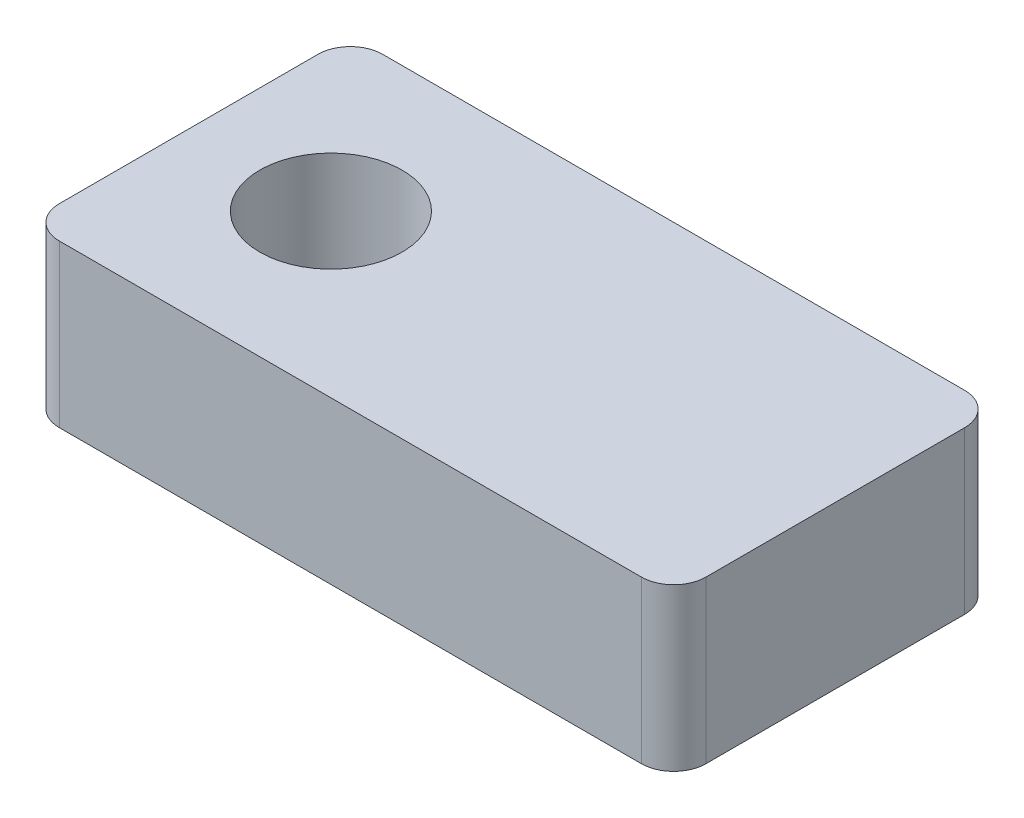
from build123d import *

# Parameters (mm, degrees)
SKETCH1_W           = 10
SKETCH1_H           = 5
SKETCH1_R           = 1.1
BOSS_EXTRUDE1_DEPTH = 2.5
FILLET1_R           = 0.5


with BuildPart() as part:
    # Sketch1 → Boss-Extrude1 (new body)
    with BuildSketch(Plane(origin=(0, 0, 0), x_dir=(1, 0, 0), z_dir=(0, 1, 0))):
        Rectangle(SKETCH1_W, SKETCH1_H)
        with Locations((-2.8, 0)):
            Circle(SKETCH1_R, mode=Mode.SUBTRACT)
    extrude(amount=BOSS_EXTRUDE1_DEPTH)

    # Fillet1
    fillet1_edges = [part.edges().sort_by_distance(p)[0] for p in [
        (5, 1.25, 2.5),
        (-5, 1.25, 2.5),
        (-5, 1.25, -2.5),
        (5, 1.25, -2.5),
    ]]
    fillet(fillet1_edges, radius=FILLET1_R)


solid = part.part
